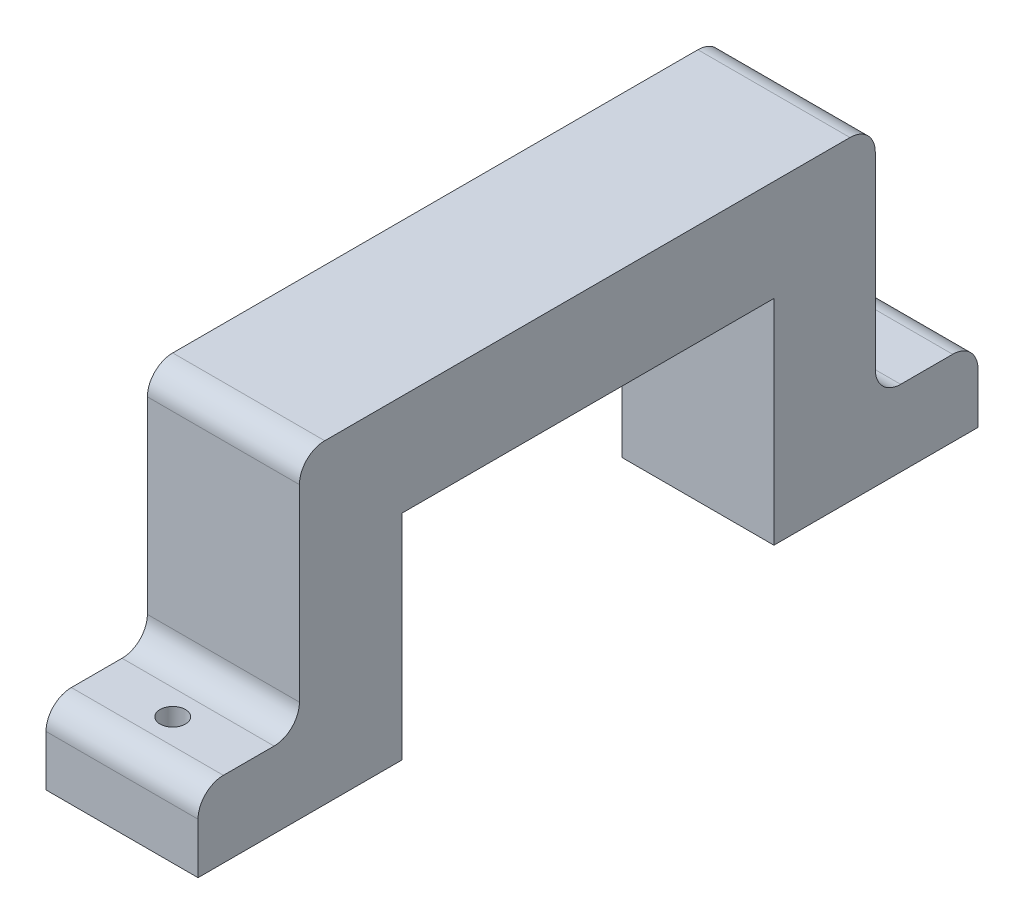
from build123d import *

# Parameters (mm, degrees)
BOSS_EXTRUDE1_DEPTH = 9.525
CUT_EXTRUDE1_REACH  = 6.763
SKETCH2_R           = 0.508
SKETCH2_R_2         = 0.79375
SKETCH3_R           = 0.508
CUT_EXTRUDE2_DEPTH  = 6.35
FILLET1_R           = 1.5875


with BuildPart() as part:
    # Sketch1 → Boss-Extrude1 (new body)
    with BuildSketch(Plane(origin=(0, 0, 0), x_dir=(0, 0, -1), z_dir=(1, 0, 0))):
        Polygon((0, 0), (12.7847852, 0), (12.7847852, 13.390245), (36.0778552, 13.390245), (36.0778552, 0), (48.8626404, 0), (48.8626404, 4.7625), (42.4278552, 4.7625), (42.4278552, 19.740245), (41.4309052, 19.740245), (6.3509652, 19.740245), (6.3509652, 4.7625), (0, 4.7625), align=None)
    extrude(amount=BOSS_EXTRUDE1_DEPTH)

    # Sketch2 → Cut-Extrude1 (cut, up to next)
    with BuildSketch(Plane(origin=(0, 4.7625, 0), x_dir=(1, 0, 0), z_dir=(0, 1, 0)), mode=Mode.PRIVATE) as cut_extrude1_sk1:
        with Locations((4.7625, 45.6876404)):
            Circle(SKETCH2_R)
    cut_extrude1_tool1 = extrude(cut_extrude1_sk1.sketch, amount=-CUT_EXTRUDE1_REACH, mode=Mode.PRIVATE) & part.part
    add(cut_extrude1_tool1.solids().sort_by_distance((4.7625, 4.7625, -45.68764))[0], mode=Mode.SUBTRACT)
    # Sketch2 → Cut-Extrude1 (cut, up to next)
    with BuildSketch(Plane(origin=(0, 4.7625, 0), x_dir=(1, 0, 0), z_dir=(0, 1, 0)), mode=Mode.PRIVATE) as cut_extrude1_sk2:
        with Locations((4.7625, 3.1756604)):
            Circle(SKETCH2_R_2)
    cut_extrude1_tool2 = extrude(cut_extrude1_sk2.sketch, amount=-CUT_EXTRUDE1_REACH, mode=Mode.PRIVATE) & part.part
    add(cut_extrude1_tool2.solids().sort_by_distance((4.7625, 4.7625, -3.17566))[0], mode=Mode.SUBTRACT)

    # Sketch3 → Cut-Extrude2 (cut)
    with BuildSketch(Plane.ZY):
        with Locations((-38.3232152, 6.68528)):
            Circle(SKETCH3_R)
        with Locations((-10.5229152, 6.6951225)):
            Circle(SKETCH3_R)
    extrude(amount=-CUT_EXTRUDE2_DEPTH, mode=Mode.SUBTRACT)

    # Fillet1
    fillet1_edges = [part.edges().sort_by_distance(p)[0] for p in [
        (4.7625, 4.7625, 0),
        (4.7625, 4.7625, -6.3509652),
        (4.7625, 19.740245, -6.3509652),
        (4.7625, 19.740245, -42.4278552),
        (4.7625, 4.7625, -42.4278552),
        (4.7625, 4.7625, -48.8626404),
    ]]
    fillet(fillet1_edges, radius=FILLET1_R)


solid = part.part
